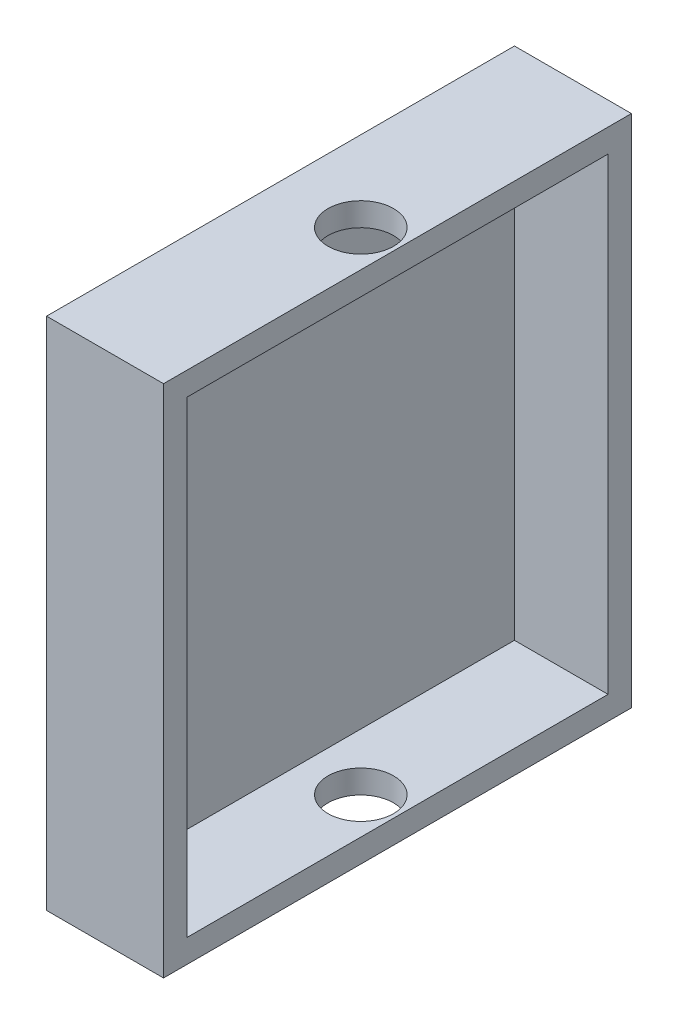
from build123d import *

# Parameters (mm, degrees)
SKETCH2_W           = 100
SKETCH2_H           = 110
BOSS_EXTRUDE1_DEPTH = 5
SKETCH2_3_W         = 100
SKETCH2_3_H         = 110
SKETCH2_3_W_2       = 90
SKETCH2_3_H_2       = 100
BOSS_EXTRUDE2_DEPTH = 25
SKETCH3_R           = 7
CUT_EXTRUDE1_DEPTH  = 124.389626793


with BuildPart() as part:
    # Sketch2 → Boss-Extrude1 (new body)
    with BuildSketch(Plane(origin=(0, 0, 0), x_dir=(0, 0, -1), z_dir=(1, 0, 0))):
        Rectangle(SKETCH2_W, SKETCH2_H)
    extrude(amount=BOSS_EXTRUDE1_DEPTH)

    # Sketch2_3 → Boss-Extrude2 (add)
    with BuildSketch(Plane(origin=(0, 0, 0), x_dir=(0, 0, -1), z_dir=(1, 0, 0))):
        Rectangle(SKETCH2_3_W, SKETCH2_3_H)
        Rectangle(SKETCH2_3_W_2, SKETCH2_3_H_2, mode=Mode.SUBTRACT)
    extrude(amount=BOSS_EXTRUDE2_DEPTH)

    # Sketch3 → Cut-Extrude1 (cut, through all)
    with BuildSketch(Plane.XZ.offset(55)):
        with Locations((17.16, 0)):
            Circle(SKETCH3_R)
    extrude(amount=-CUT_EXTRUDE1_DEPTH, mode=Mode.SUBTRACT)


solid = part.part
